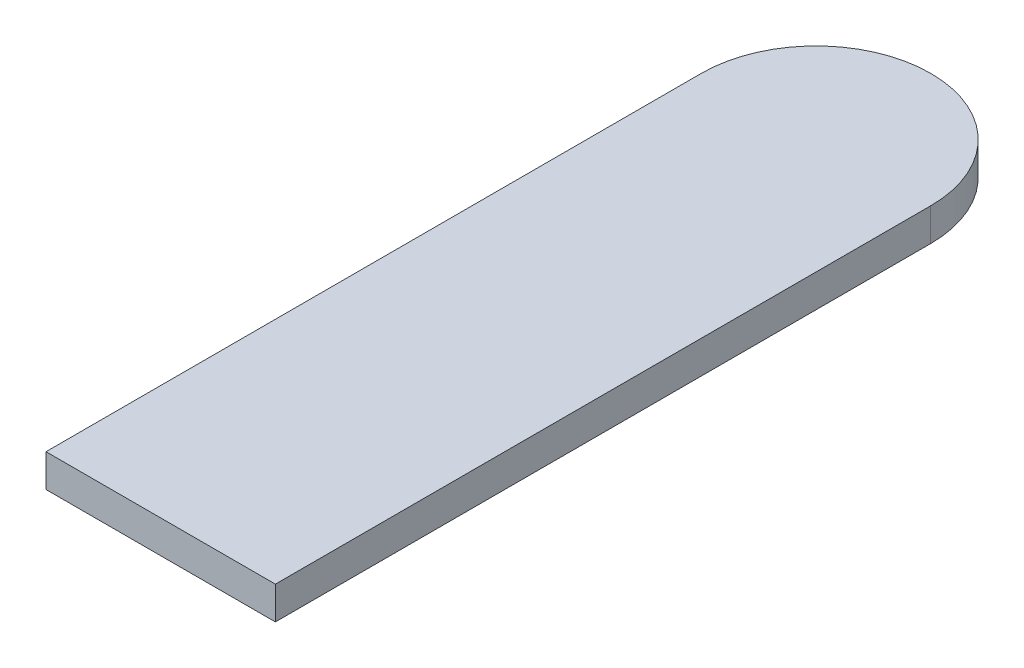
from build123d import *

# Parameters (mm, degrees)
BOSS_EXTRUDE1_DEPTH = 1


with BuildPart() as part:
    # Sketch1 → Boss-Extrude1 (new body)
    with BuildSketch(Plane(origin=(0, 0, 0), x_dir=(1, 0, 0), z_dir=(0, 1, 0))):
        with BuildLine():
            Line((0, 0), (-7, 0))
            Line((-7, 0), (-7, 20))
            ThreePointArc((-7, 20), (-3.5, 23.5), (0, 20))
            Line((0, 20), (0, 0))
        make_face()
    extrude(amount=BOSS_EXTRUDE1_DEPTH)


solid = part.part
